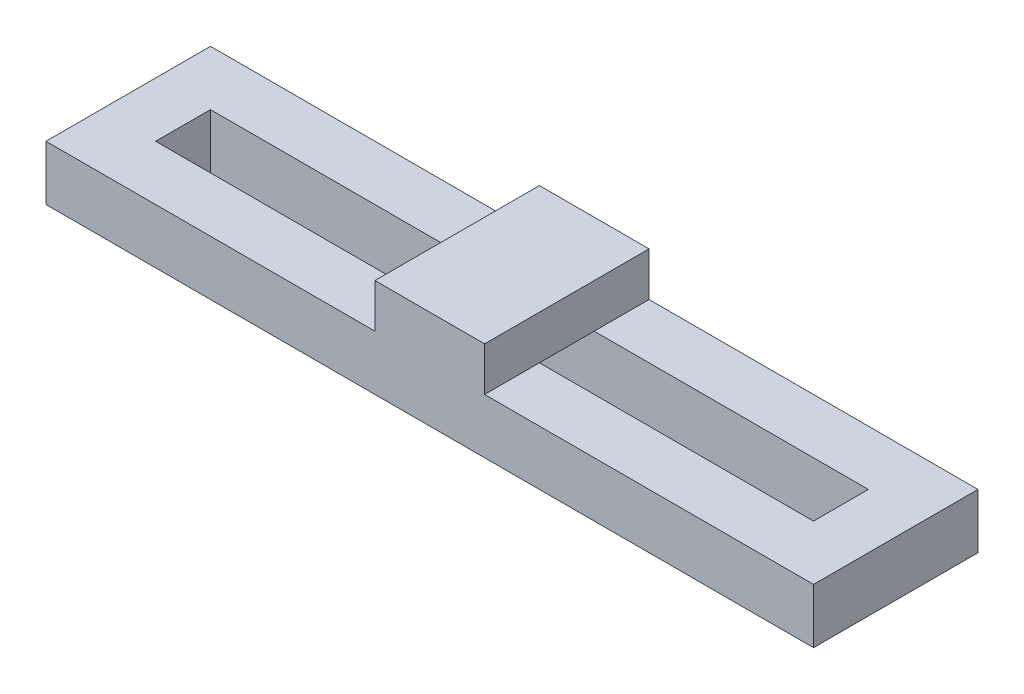
from build123d import *

# Parameters (mm, degrees)
SKETCH2_W           = 70
SKETCH2_H           = 15
SKETCH2_W_2         = 60
SKETCH2_H_2         = 5
BOSS_EXTRUDE3_DEPTH = 5
SKETCH3_W           = 10
SKETCH3_H           = 15
BOSS_EXTRUDE4_DEPTH = 4


with BuildPart() as part:
    # Sketch2 → Boss-Extrude3 (new body)
    with BuildSketch(Plane(origin=(0, 0, 0), x_dir=(1, 0, 0), z_dir=(0, 1, 0))):
        Rectangle(SKETCH2_W, SKETCH2_H)
        Rectangle(SKETCH2_W_2, SKETCH2_H_2, mode=Mode.SUBTRACT)
    extrude(amount=BOSS_EXTRUDE3_DEPTH)

    # Sketch3 → Boss-Extrude4 (add)
    with BuildSketch(Plane(origin=(0, 5, 0), x_dir=(1, 0, 0), z_dir=(0, 1, 0))):
        Rectangle(SKETCH3_W, SKETCH3_H)
    extrude(amount=BOSS_EXTRUDE4_DEPTH)


solid = part.part
